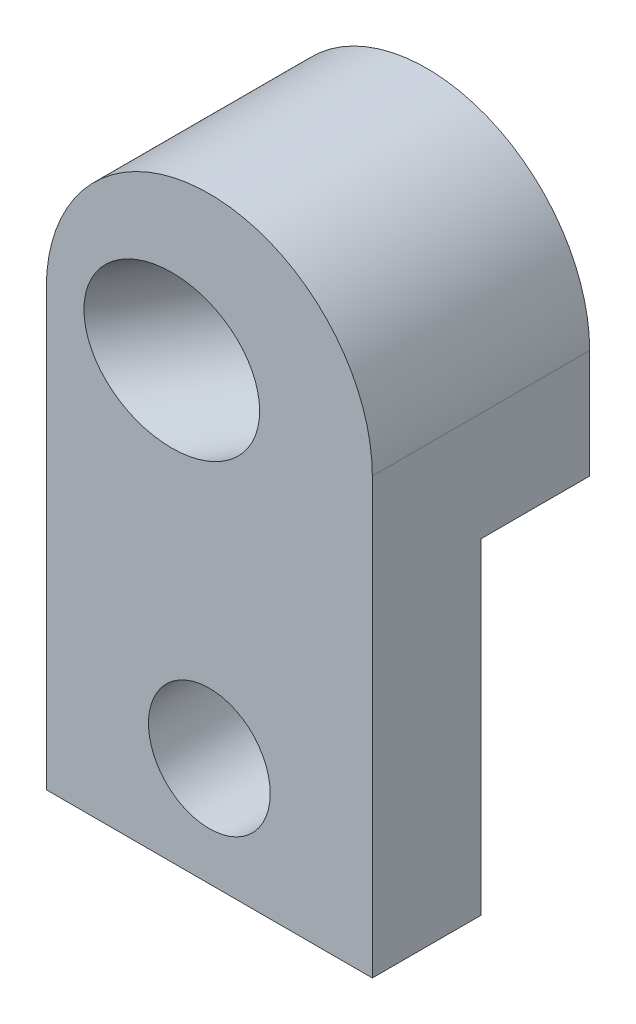
from build123d import *

# Parameters (mm, degrees)
SKETCH2_R           = 2.8
BOSS_EXTRUDE1_DEPTH = 5
BOSS_EXTRUDE2_DEPTH = 5
SKETCH4_R           = 3.5
CUT_EXTRUDE1_DEPTH  = 10


with BuildPart() as part:
    # Sketch2 → Boss-Extrude1 (new body)
    with BuildSketch(Plane.XY):
        with BuildLine():
            Line((0, 0), (15, 0))
            Line((15, 0), (15, 20))
            ThreePointArc((15, 20), (7.5, 27.5), (0, 20))
            Line((0, 20), (0, 0))
        make_face()
        with Locations((7.5, 5)):
            Circle(SKETCH2_R, mode=Mode.SUBTRACT)
    extrude(amount=BOSS_EXTRUDE1_DEPTH)

    # Sketch3 → Boss-Extrude2 (add)
    with BuildSketch(Plane(origin=(0, 0, 0), x_dir=(-1, 0, 0), z_dir=(0, 0, -1))):
        with BuildLine():
            Line((-15, 20), (-15, 15))
            Line((-15, 15), (0, 15))
            Line((0, 15), (0, 20))
            ThreePointArc((0, 20), (-7.5, 27.5), (-15, 20))
        make_face()
    extrude(amount=BOSS_EXTRUDE2_DEPTH)

    # Sketch4 → Cut-Extrude1 (cut)
    with BuildSketch(Plane(origin=(-2.165063509, 0, 3.75), x_dir=(0, -1, 0), z_dir=(-0.5, 0, 0.866025404))):
        with Locations((-20, 7.5)):
            Circle(SKETCH4_R)
    extrude(amount=-CUT_EXTRUDE1_DEPTH, mode=Mode.SUBTRACT)


solid = part.part
